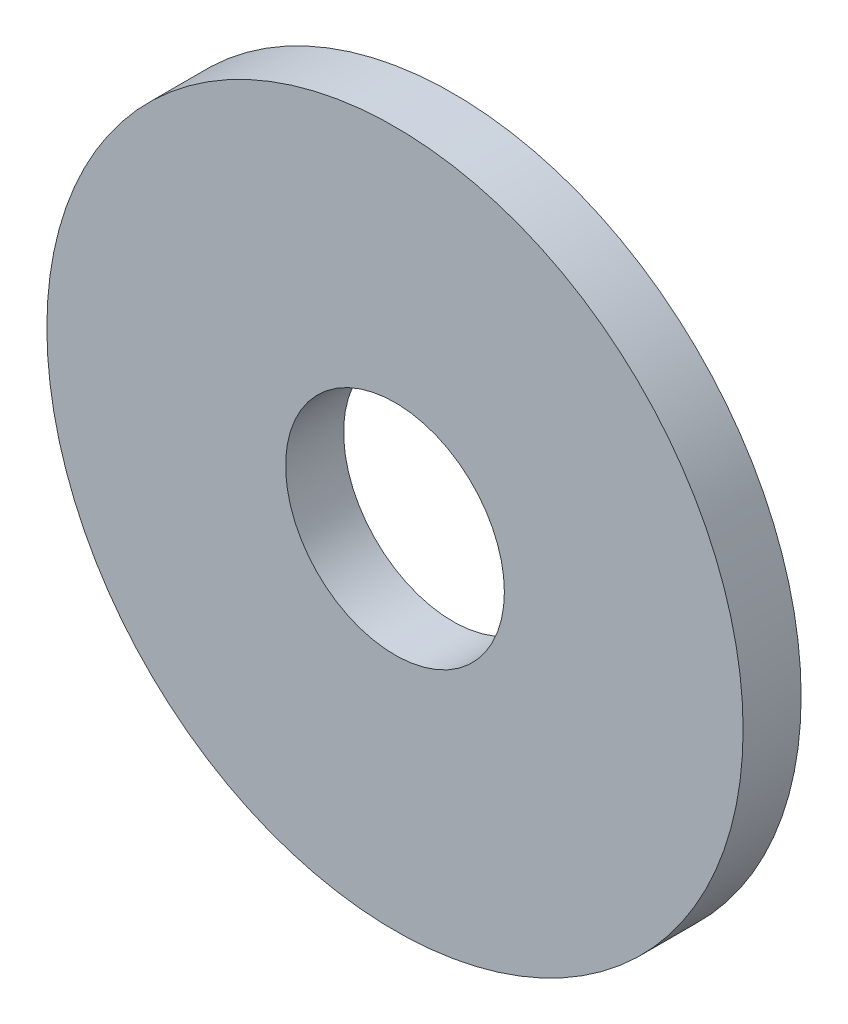
from build123d import *

# Parameters (mm, degrees)
SKETCH1_R           = 9.525
SKETCH1_R_2         = 2.99299376
BOSS_EXTRUDE1_DEPTH = 1.5875


with BuildPart() as part:
    # Sketch1 → Boss-Extrude1 (new body)
    with BuildSketch(Plane.XY):
        Circle(SKETCH1_R)
        Circle(SKETCH1_R_2, mode=Mode.SUBTRACT)
    extrude(amount=BOSS_EXTRUDE1_DEPTH)


solid = part.part
